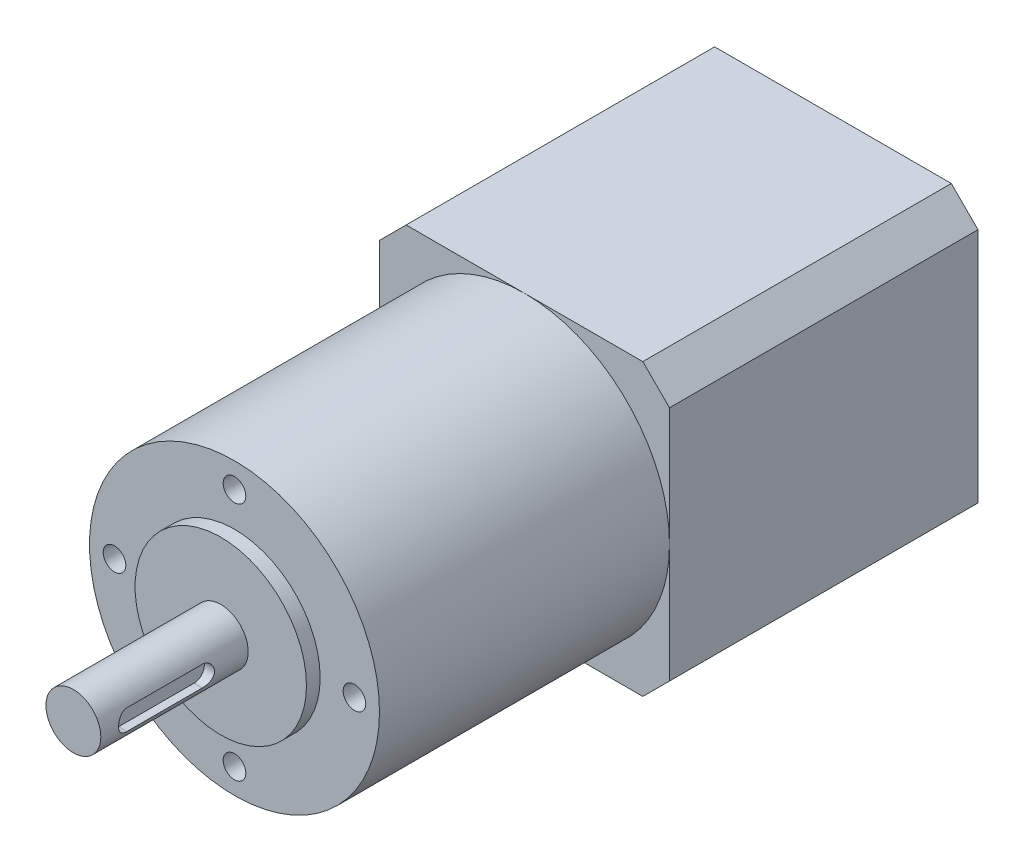
from build123d import *

# Parameters (mm, degrees)
BOSS_EXTRUDE1_DEPTH = 45
SKETCH4_R           = 1.65
CUT_EXTRUDE1_DEPTH  = 7
CUT_EXTRUDE2_DEPTH  = 1.5


with BuildPart() as part:
    # Sketch1 → Boss-Extrude1 (new body)
    with BuildSketch(Plane.XY):
        Polygon((-21.15, 17.260912703), (-17.260912703, 21.15), (17.260912703, 21.15), (21.15, 17.260912703), (21.15, -17.260912703), (17.260912703, -21.15), (-17.260912703, -21.15), (-21.15, -17.260912703), align=None)
    extrude(amount=BOSS_EXTRUDE1_DEPTH)

    # Sketch3 → Revolve1 (revolve)
    with BuildSketch(Plane(origin=(0, 0, 0), x_dir=(0, 0, -1), z_dir=(1, 0, 0))):
        Polygon((-45, 21.15), (-87.3, 21.15), (-87.3, 12.5), (-89.3, 12.5), (-89.3, 4), (-110.8, 4), (-110.8, 0), (-45, 0), align=None)
    revolve(axis=Axis((0, 0, 110.8), (0, 0, -1)))

    # Sketch4 → Cut-Extrude1 (cut)
    with BuildSketch(Plane.XY.offset(87.3)):
        with Locations((0, 17.5)):
            Circle(SKETCH4_R)
        with Locations((17.5, 0)):
            Circle(SKETCH4_R)
        with Locations((0, -17.5)):
            Circle(SKETCH4_R)
        with Locations((-17.5, 0)):
            Circle(SKETCH4_R)
    extrude(amount=-CUT_EXTRUDE1_DEPTH, mode=Mode.SUBTRACT)

    # Sketch5 → Cut-Extrude2 (cut)
    with BuildSketch(Plane(origin=(4, 0, 0), x_dir=(0, 0, -1), z_dir=(1, 0, 0))):
        with BuildLine():
            Line((-106.7, 1.5), (-95.7, 1.5))
            ThreePointArc((-95.7, 1.5), (-94.2, 0), (-95.7, -1.5))
            Line((-95.7, -1.5), (-106.7, -1.5))
            ThreePointArc((-106.7, -1.5), (-108.2, 0), (-106.7, 1.5))
        make_face()
    extrude(amount=-CUT_EXTRUDE2_DEPTH, mode=Mode.SUBTRACT)


solid = part.part
